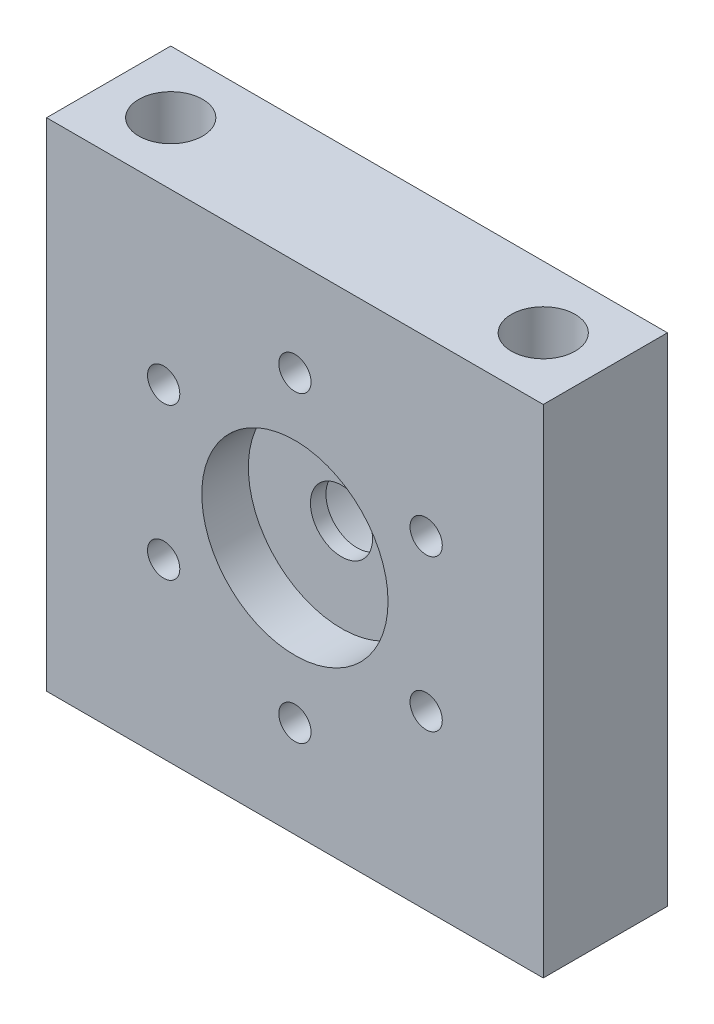
from build123d import *

# Parameters (mm, degrees)
SKETCH1_W           = 50.8
SKETCH1_H           = 12.7
BOSS_EXTRUDE1_DEPTH = 50.8
SKETCH2_R           = 3.175
CUT_EXTRUDE1_DEPTH  = 13.7
SKETCH3_R           = 9.525
CUT_EXTRUDE2_DEPTH  = 4.7625
SKETCH4_R           = 3.2639
CUT_EXTRUDE3_DEPTH  = 12.7
SKETCH5_R           = 1.65
CUT_EXTRUDE4_DEPTH  = 13.7
SKETCH6_R           = 7.62
CUT_EXTRUDE5_DEPTH  = 6.35


with BuildPart() as part:
    # Sketch1 → Boss-Extrude1 (new body)
    with BuildSketch(Plane(origin=(0, 0, 0), x_dir=(1, 0, 0), z_dir=(0, 1, 0))):
        with Locations((25.4, 6.35)):
            Rectangle(SKETCH1_W, SKETCH1_H)
    extrude(amount=BOSS_EXTRUDE1_DEPTH)

    # Sketch2 → Cut-Extrude1 (cut, through all)
    with BuildSketch(Plane.XY):
        with Locations((25.4, 25.4)):
            Circle(SKETCH2_R)
    extrude(amount=-CUT_EXTRUDE1_DEPTH, mode=Mode.SUBTRACT)

    # Sketch3 → Cut-Extrude2 (cut)
    with BuildSketch(Plane.XY):
        with Locations((25.4, 25.4)):
            Circle(SKETCH3_R)
    extrude(amount=-CUT_EXTRUDE2_DEPTH, mode=Mode.SUBTRACT)

    # Sketch4 → Cut-Extrude3 (cut)
    with BuildSketch(Plane(origin=(0, 50.8, 0), x_dir=(1, 0, 0), z_dir=(0, 1, 0))):
        with Locations((6.35, 6.35)):
            Circle(SKETCH4_R)
        with Locations((44.45, 6.35)):
            Circle(SKETCH4_R)
    cut_extrude3 = extrude(amount=-CUT_EXTRUDE3_DEPTH, mode=Mode.SUBTRACT)

    # Mirror1: Cut-Extrude3 across plane
    add(cut_extrude3.mirror(Plane.ZX.offset(25.4)), mode=Mode.SUBTRACT)

    # Sketch5 → Cut-Extrude4 (cut, through all)
    with BuildSketch(Plane.XY):
        with Locations((25.4, 40.9)):
            Circle(SKETCH5_R)
        with Locations((38.823393759, 33.15)):
            Circle(SKETCH5_R)
        with Locations((38.823393759, 17.65)):
            Circle(SKETCH5_R)
        with Locations((25.4, 9.9)):
            Circle(SKETCH5_R)
        with Locations((11.976606241, 17.65)):
            Circle(SKETCH5_R)
        with Locations((11.976606241, 33.15)):
            Circle(SKETCH5_R)
    extrude(amount=-CUT_EXTRUDE4_DEPTH, mode=Mode.SUBTRACT)

    # Sketch6 → Cut-Extrude5 (cut)
    with BuildSketch(Plane(origin=(0, 0, -12.7), x_dir=(-1, 0, 0), z_dir=(0, 0, -1))):
        with Locations((-25.4, 25.4)):
            Circle(SKETCH6_R)
    extrude(amount=-CUT_EXTRUDE5_DEPTH, mode=Mode.SUBTRACT)


solid = part.part
